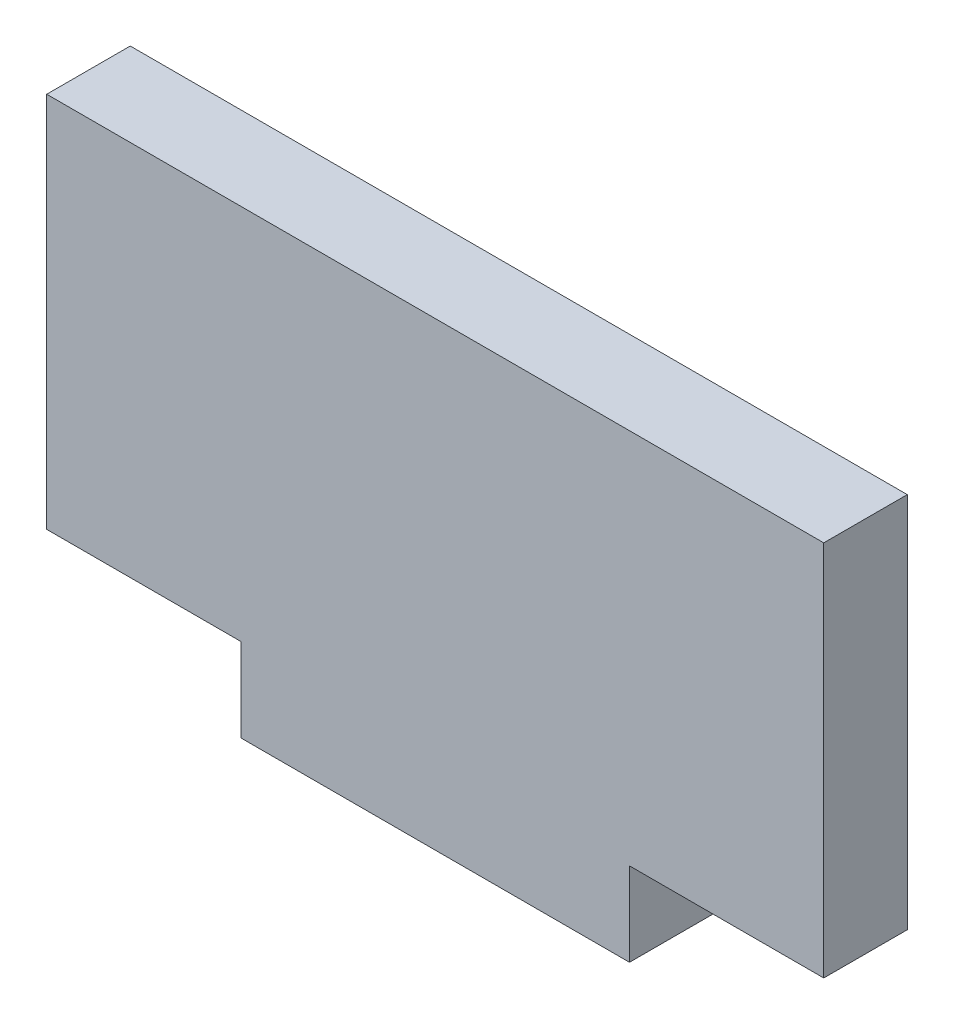
from build123d import *

# Parameters (mm, degrees)
SKETCH1_W           = 25.4
SKETCH1_H           = 5.461
BOSS_EXTRUDE1_DEPTH = 5.461


with BuildPart() as part:
    # Sketch1 → Boss-Extrude1 (new body)
    with BuildSketch(Plane.XY):
        Polygon((-25.4, 2.7305), (-12.7, 2.7305), (12.7, 2.7305), (25.4, 2.7305), (25.4, 27.3685), (-25.4, 27.3685), align=None)
        Rectangle(SKETCH1_W, SKETCH1_H)
    extrude(amount=BOSS_EXTRUDE1_DEPTH)


solid = part.part
